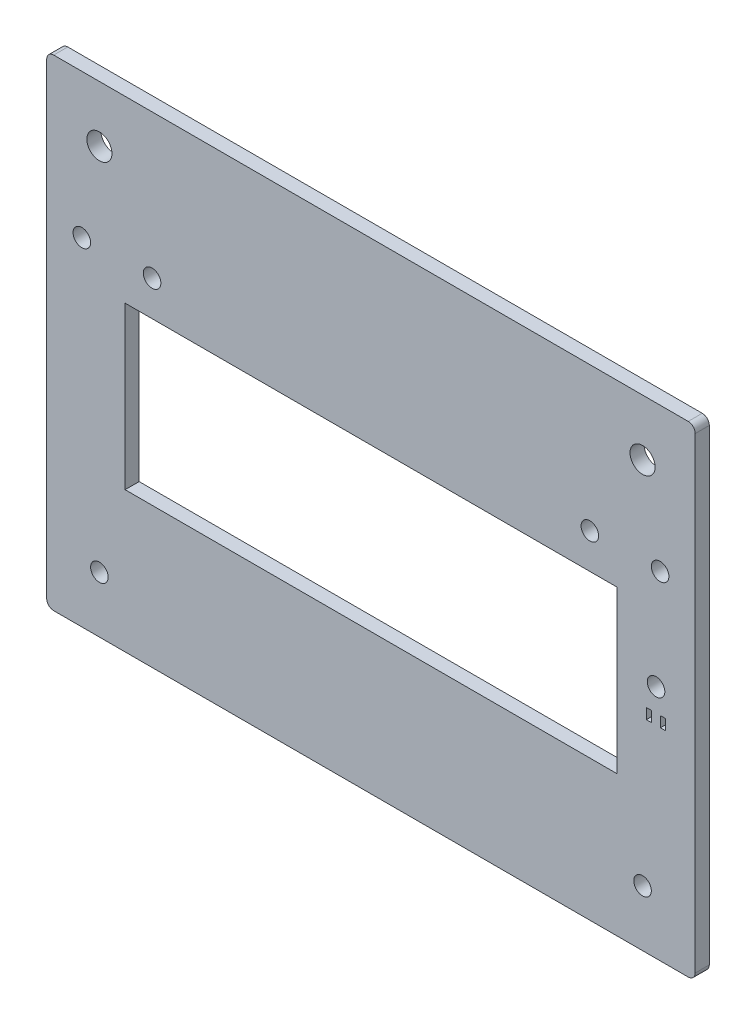
from build123d import *

# Parameters (mm, degrees)
SKETCH1_W           = 184.64
SKETCH1_H           = 137
SKETCH1_R           = 3.65
SKETCH1_R_2         = 3.57
SKETCH1_R_3         = 2.5
BOSS_EXTRUDE1_DEPTH = 4
SKETCH3_W           = 104.64
SKETCH3_H           = 20
BOSS_EXTRUDE2_DEPTH = 4
SKETCH6_R           = 3.65
CUT_EXTRUDE4_DEPTH  = 5
SKETCH8_W           = 140
SKETCH8_H           = 16
CUT_EXTRUDE6_DEPTH  = 10
FILLET5_R           = 2
SKETCH11_W          = 184.64
SKETCH11_H          = 15
SKETCH11_R          = 2.5
BOSS_EXTRUDE4_DEPTH = 4
SKETCH12_R          = 2.5
CUT_EXTRUDE8_DEPTH  = 5
SKETCH13_R          = 2.5
CUT_EXTRUDE9_DEPTH  = 10
SKETCH14_W          = 1.5
SKETCH14_H          = 3
CUT_EXTRUDE10_DEPTH = 5


with BuildPart() as part:
    # Sketch1 → Boss-Extrude1 (new body)
    with BuildSketch(Plane.XY):
        with Locations((92.32, 68.5)):
            Rectangle(SKETCH1_W, SKETCH1_H)
        with Locations((15, 16)):
            Circle(SKETCH1_R, mode=Mode.SUBTRACT)
        with Locations((169.64, 16)):
            Circle(SKETCH1_R, mode=Mode.SUBTRACT)
        with Locations((15, 121)):
            Circle(SKETCH1_R_2, mode=Mode.SUBTRACT)
        with Locations((30, 96)):
            Circle(SKETCH1_R_3, mode=Mode.SUBTRACT)
        with Locations((169.64, 121)):
            Circle(SKETCH1_R_2, mode=Mode.SUBTRACT)
        with Locations((154.64, 96)):
            Circle(SKETCH1_R_3, mode=Mode.SUBTRACT)
        Polygon((40, 106), (40, 86), (22.32, 86), (22.32, 56), (162.32, 56), (162.32, 86), (144.64, 86), (144.64, 106), align=None, mode=Mode.SUBTRACT)
    extrude(amount=BOSS_EXTRUDE1_DEPTH)

    # Sketch3 → Boss-Extrude2 (add)
    with BuildSketch(Plane.XY.offset(4)):
        with Locations((92.32, 96)):
            Rectangle(SKETCH3_W, SKETCH3_H)
    extrude(amount=-BOSS_EXTRUDE2_DEPTH)

    # Sketch6 → Cut-Extrude4 (cut, through all)
    with BuildSketch(Plane.XY.offset(4)):
        with Locations((67.32, 16)):
            Circle(SKETCH6_R)
        with Locations((117.32, 16)):
            Circle(SKETCH6_R)
    extrude(amount=-CUT_EXTRUDE4_DEPTH, mode=Mode.SUBTRACT)

    # Sketch8 → Cut-Extrude6 (cut)
    with BuildSketch(Plane.XY.offset(4)):
        with Locations((92.32, 48)):
            Rectangle(SKETCH8_W, SKETCH8_H)
    extrude(amount=-CUT_EXTRUDE6_DEPTH, mode=Mode.SUBTRACT)

    # Fillet5
    fillet5_edges = [part.edges().sort_by_distance(p)[0] for p in [
        (0, 137, 2),
        (184.64, 137, 2),
        (184.64, 0, 2),
        (0, 0, 2),
    ]]
    fillet(fillet5_edges, radius=FILLET5_R)

    # Sketch11 → Boss-Extrude4 (add, through all)
    with BuildSketch(Plane.XY.offset(4)):
        with Locations((92.32, 16)):
            Rectangle(SKETCH11_W, SKETCH11_H)
        with Locations((15, 16)):
            Circle(SKETCH11_R, mode=Mode.SUBTRACT)
        with Locations((169.64, 16)):
            Circle(SKETCH11_R, mode=Mode.SUBTRACT)
    extrude(amount=-BOSS_EXTRUDE4_DEPTH)

    # Sketch12 → Cut-Extrude8 (cut, through all)
    with BuildSketch(Plane.XY.offset(4)):
        with Locations((10, 96)):
            Circle(SKETCH12_R)
        with Locations((174.64, 96)):
            Circle(SKETCH12_R)
    extrude(amount=-CUT_EXTRUDE8_DEPTH, mode=Mode.SUBTRACT)

    # Sketch13 → Cut-Extrude9 (cut)
    with BuildSketch(Plane.XY.offset(4)):
        with Locations((173.48, 67)):
            Circle(SKETCH13_R)
    extrude(amount=-CUT_EXTRUDE9_DEPTH, mode=Mode.SUBTRACT)

    # Sketch14 → Cut-Extrude10 (cut, through all)
    with BuildSketch(Plane.XY.offset(4)):
        with Locations((171.48, 59)):
            Rectangle(SKETCH14_W, SKETCH14_H)
        with Locations((175.48, 59)):
            Rectangle(SKETCH14_W, SKETCH14_H)
    extrude(amount=-CUT_EXTRUDE10_DEPTH, mode=Mode.SUBTRACT)


solid = part.part
